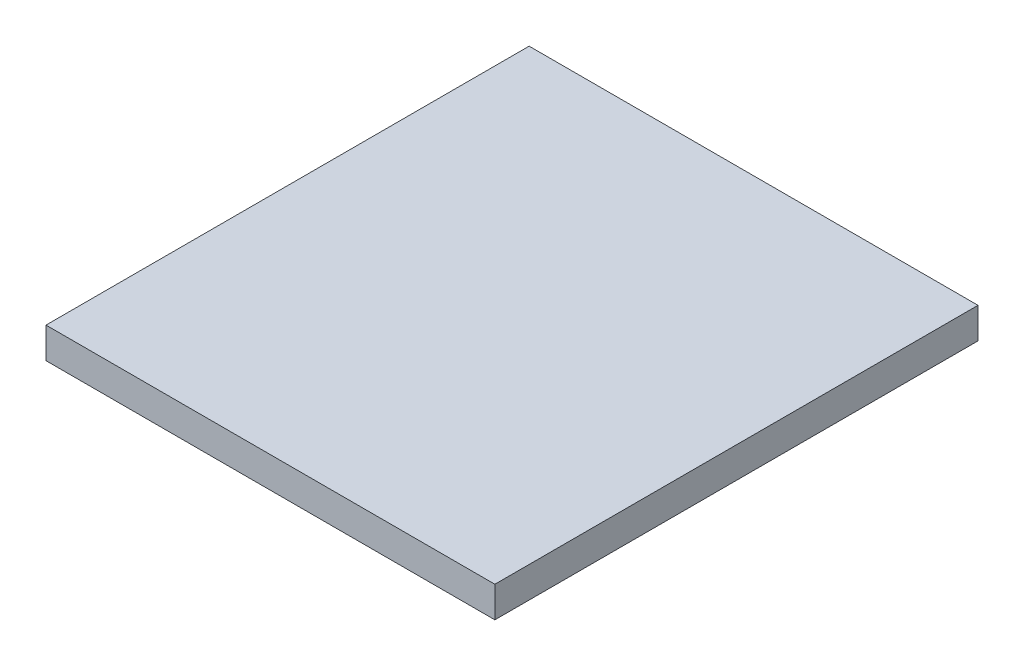
from build123d import *

# Parameters (mm, degrees)
SKETCH_1_W      = 262
SKETCH_1_H      = 282
EXTRUDE_1_DEPTH = 18


with BuildPart() as part:
    # Эскиз1 → Бобышка-Вытянуть1 (new body)
    with BuildSketch(Plane(origin=(0, 0, 0), x_dir=(1, 0, 0), z_dir=(0, 1, 0))):
        Rectangle(SKETCH_1_W, SKETCH_1_H)
    extrude(amount=EXTRUDE_1_DEPTH)


solid = part.part
